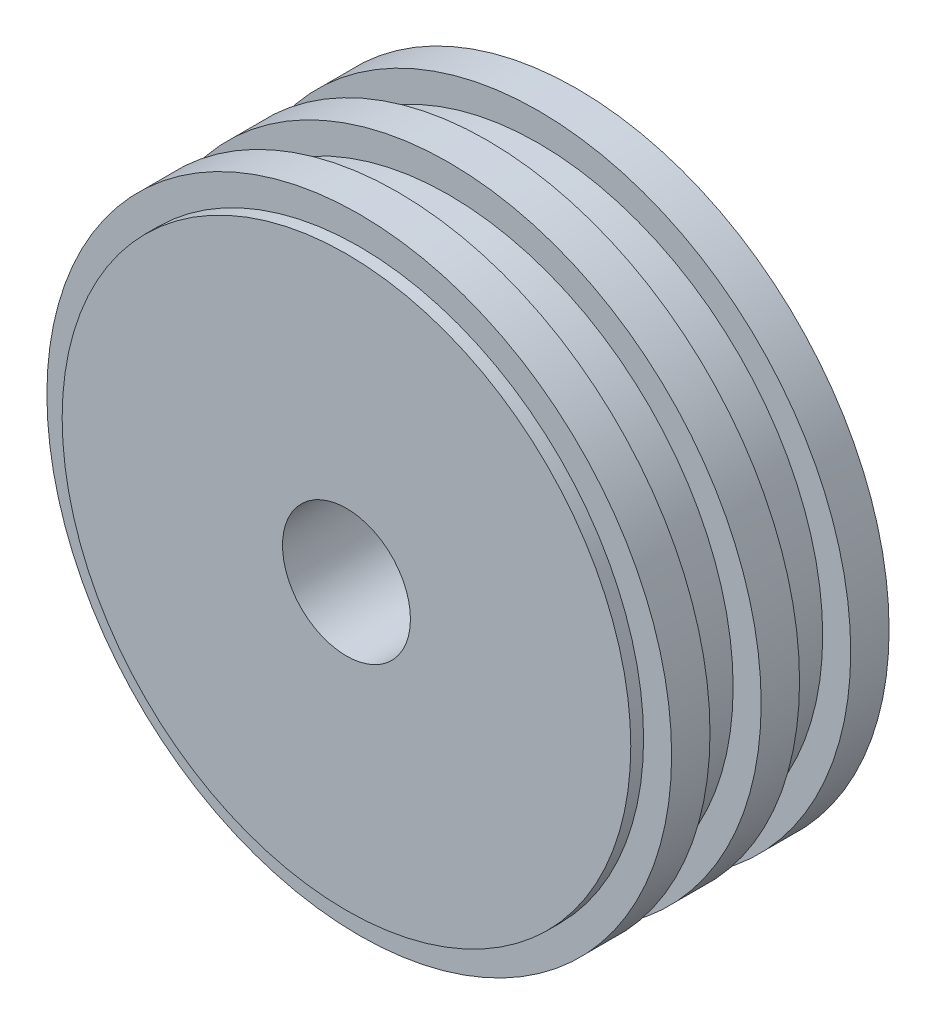
from build123d import *

# Parameters (mm, degrees)
SKETCH1_R           = 66.675
SKETCH1_R_2         = 15
BOSS_EXTRUDE1_DEPTH = 57
SKETCH2_R           = 73.25
SKETCH2_R_2         = 66.675
BOSS_EXTRUDE2_DEPTH = 9
LPATTERN1_COUNT     = 3
LPATTERN1_PITCH     = 21


with BuildPart() as part:
    # Sketch1 → Boss-Extrude1 (new body)
    with BuildSketch(Plane.XY):
        Circle(SKETCH1_R)
        Circle(SKETCH1_R_2, mode=Mode.SUBTRACT)
    extrude(amount=-BOSS_EXTRUDE1_DEPTH)

    # Sketch2 → Boss-Extrude2 (add)
    with BuildSketch(Plane.XY.offset(-3)):
        Circle(SKETCH2_R)
        Circle(SKETCH2_R_2, mode=Mode.SUBTRACT)
    boss_extrude2 = extrude(amount=-BOSS_EXTRUDE2_DEPTH)

    # LPattern1: Boss-Extrude2 ×3
    with Locations(*[(0, 0, -i * LPATTERN1_PITCH) for i in range(1, LPATTERN1_COUNT)]):
        add(boss_extrude2)


solid = part.part
